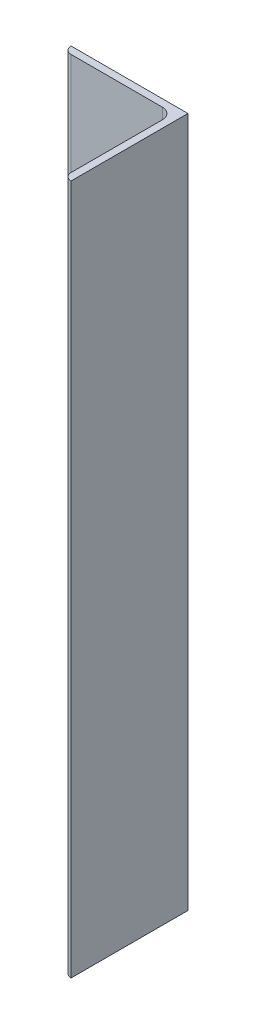
from build123d import *

# Parameters (mm, degrees)
HIERRO_ANGULAR_2_X_2_X_0_125_1_DEPTH = 300


with BuildPart() as part:
    # Sketch11 → Hierro angular 2 X 2 X 0.125(1) (new body)
    with BuildSketch(Plane(origin=(0, -150, 0), x_dir=(-1, 0, 0), z_dir=(0, 1, 0))):
        with BuildLine():
            Line((0, 0), (0, 50.8))
            Line((0, 50.8), (0.00508, 50.8))
            ThreePointArc((0.00508, 50.8), (2.246551928, 49.871551928), (3.175, 47.63008))
            Line((3.175, 47.63008), (3.175, 7.9375))
            ThreePointArc((3.175, 7.9375), (4.569903955, 4.569903955), (7.9375, 3.175))
            Line((7.9375, 3.175), (47.63008, 3.175))
            ThreePointArc((47.63008, 3.175), (49.871551928, 2.246551928), (50.8, 0.00508))
            Line((50.8, 0.00508), (50.8, 0))
            Line((50.8, 0), (0, 0))
        make_face()
    extrude(amount=HIERRO_ANGULAR_2_X_2_X_0_125_1_DEPTH)


solid = part.part
